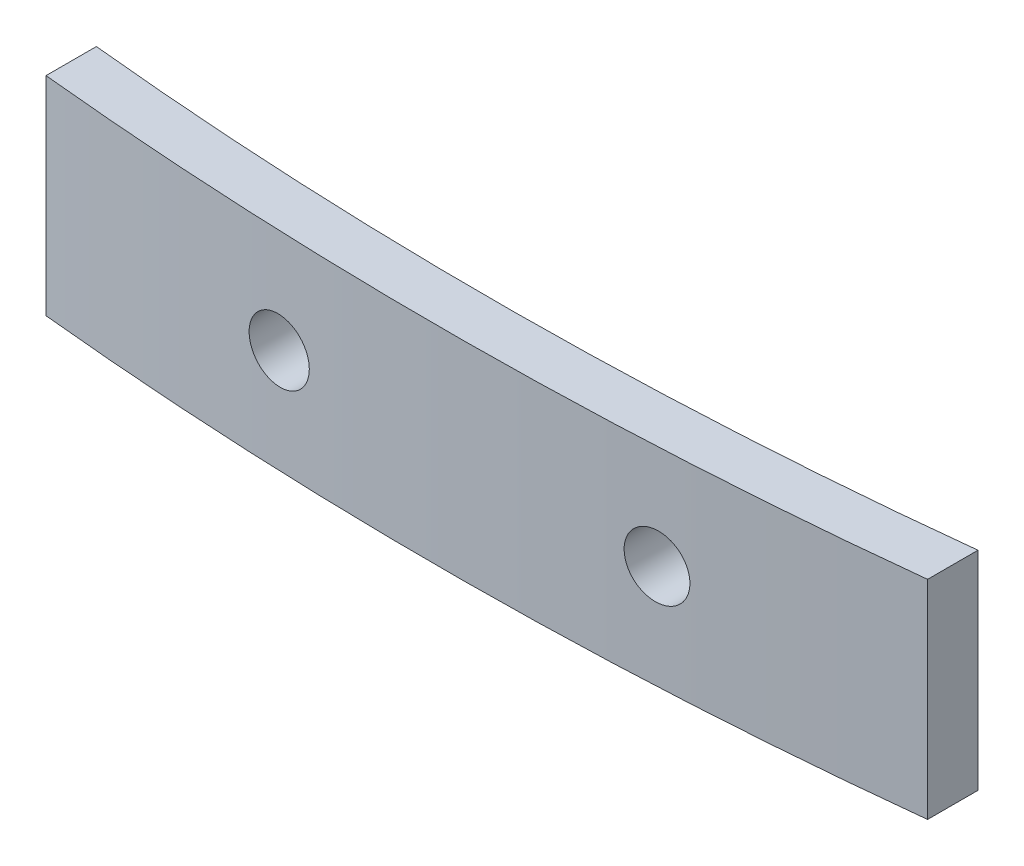
from build123d import *

# Parameters (mm, degrees)
BOSS_EXTRUDE1_DEPTH     = 8.3
SKETCH2_R               = 1.25
CUT_EXTRUDE1_DEPTH      = 3.700074126
CUT_EXTRUDE1_DEPTH_BACK = 1.323830371


with BuildPart() as part:
    # Sketch1 → Boss-Extrude1 (new body)
    with BuildSketch(Plane(origin=(0, 0, 0), x_dir=(1, 0, 0), z_dir=(0, 1, 0))):
        with BuildLine():
            Line((-17.5, 0.139549674), (-17.5, -1.870543406))
            ThreePointArc((-17.5, -1.870543406), (0.004776494, -2.697812194), (17.5, -1.688491505))
            Line((17.5, -1.688491505), (17.5, 0.323830371))
            ThreePointArc((17.5, 0.323830371), (0.004893833, -0.697784194), (-17.5, 0.139549674))
        make_face()
    extrude(amount=BOSS_EXTRUDE1_DEPTH)

    # Sketch2 → Cut-Extrude1 (cut, two sides)
    with BuildSketch(Plane.XY) as cut_extrude1_sk:
        with Locations((7.5, 4.15)):
            Circle(SKETCH2_R)
        with Locations((-7.5, 4.15)):
            Circle(SKETCH2_R)
    extrude(amount=CUT_EXTRUDE1_DEPTH, mode=Mode.SUBTRACT)
    extrude(cut_extrude1_sk.sketch, amount=-CUT_EXTRUDE1_DEPTH_BACK, mode=Mode.SUBTRACT)


solid = part.part
